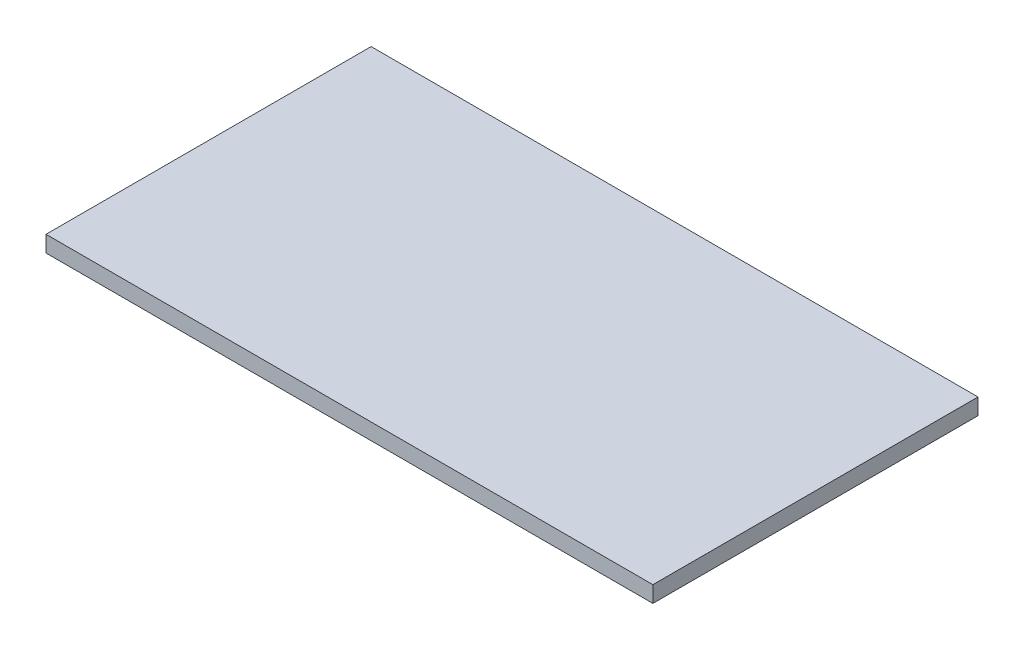
from build123d import *

# Parameters (mm, degrees)
SKIZZE1_W                       = 560
SKIZZE1_H                       = 300
AUFSATZ_LINEAR_AUSTRAGEN1_DEPTH = 15


with BuildPart() as part:
    # Skizze1 → Aufsatz-Linear austragen1 (new body)
    with BuildSketch(Plane(origin=(0, 0, 0), x_dir=(1, 0, 0), z_dir=(0, 1, 0))):
        with Locations((0, -16)):
            Rectangle(SKIZZE1_W, SKIZZE1_H)
    extrude(amount=AUFSATZ_LINEAR_AUSTRAGEN1_DEPTH)


solid = part.part
